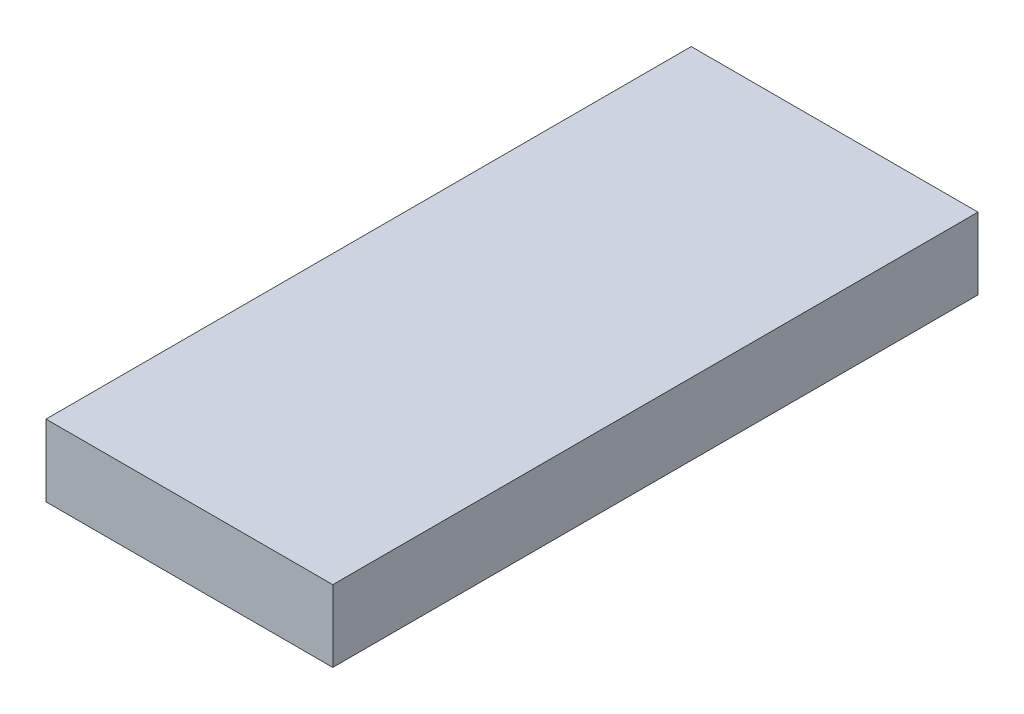
from build123d import *

# Parameters (mm, degrees)
SKETCH1_W           = 20
SKETCH1_H           = 45
BOSS_EXTRUDE1_DEPTH = 5


with BuildPart() as part:
    # Sketch1 → Boss-Extrude1 (new body)
    with BuildSketch(Plane(origin=(0, 0, 0), x_dir=(1, 0, 0), z_dir=(0, 1, 0))):
        Rectangle(SKETCH1_W, SKETCH1_H)
    extrude(amount=BOSS_EXTRUDE1_DEPTH)


solid = part.part
